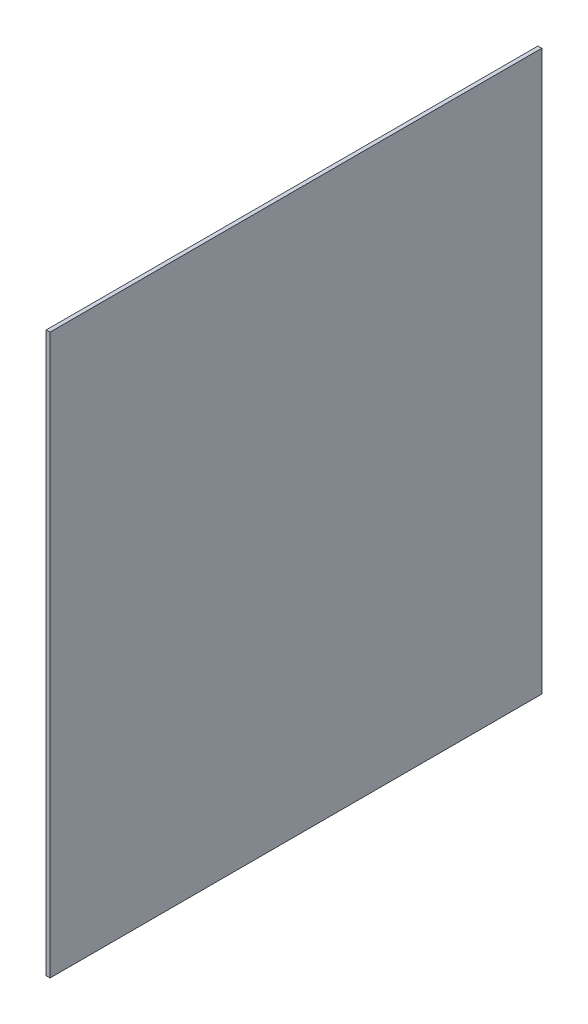
from build123d import *

# Parameters (mm, degrees)
SKETCH1_W           = 203.2
SKETCH1_H           = 231.14
BOSS_EXTRUDE1_DEPTH = 1.5875


with BuildPart() as part:
    # Sketch1 → Boss-Extrude1 (new body)
    with BuildSketch(Plane(origin=(0, 0, 0), x_dir=(0, 0, -1), z_dir=(1, 0, 0))):
        with Locations((101.6, 115.57)):
            Rectangle(SKETCH1_W, SKETCH1_H)
    extrude(amount=BOSS_EXTRUDE1_DEPTH)


solid = part.part
